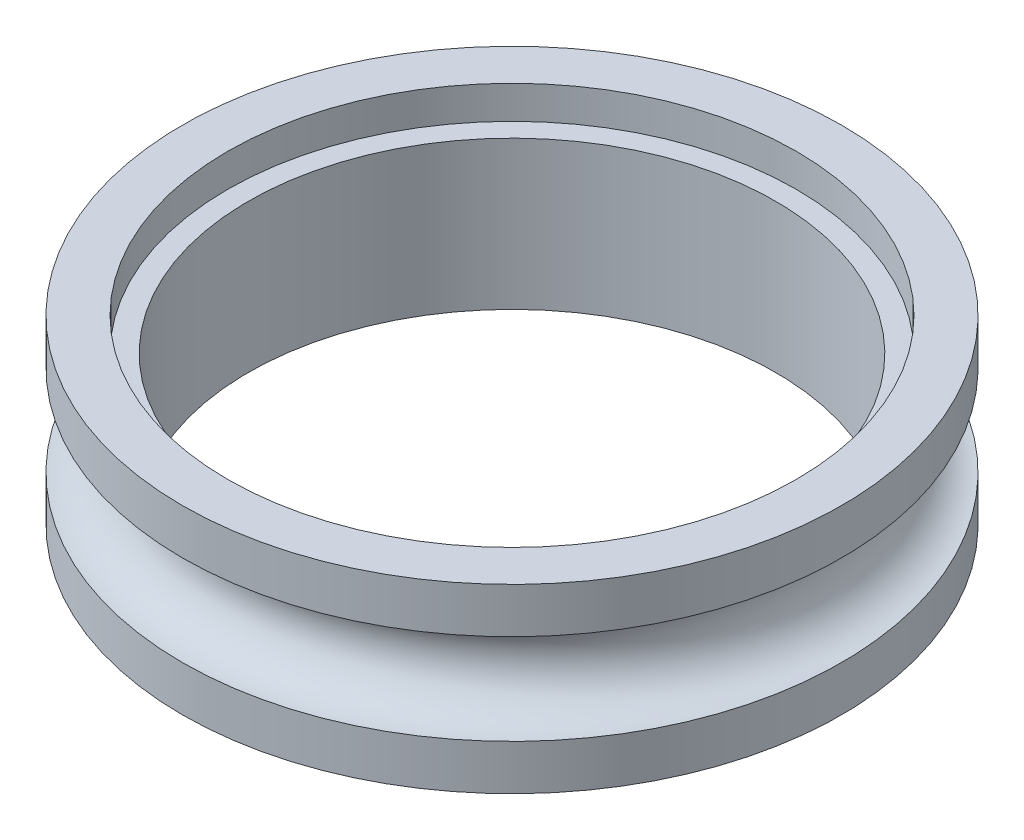
from build123d import *

# Parameters (mm, degrees)
SKETCH1_R           = 10.16
BOSS_EXTRUDE1_DEPTH = 5.588
SKETCH3_R           = 8.128
CUT_EXTRUDE1_DEPTH  = 10.16
SKETCH4_R           = 8.763
CUT_EXTRUDE2_DEPTH  = 1.016


with BuildPart() as part:
    # Sketch1 → Boss-Extrude1 (new body)
    with BuildSketch(Plane(origin=(0, 0, 0), x_dir=(1, 0, 0), z_dir=(0, 1, 0))):
        Circle(SKETCH1_R)
    extrude(amount=BOSS_EXTRUDE1_DEPTH)

    # Sketch2 → Cut-Revolve1 (revolve, cut)
    with BuildSketch(Plane.XY):
        with BuildLine():
            Line((-10.16, 4.191), (-10.16, 1.397))
            ThreePointArc((-10.16, 1.397), (-8.763, 2.794), (-10.16, 4.191))
        make_face()
    revolve(axis=Axis((0, 5.588, 0), (0, -1, 0)), mode=Mode.SUBTRACT)

    # Sketch3 → Cut-Extrude1 (cut)
    with BuildSketch(Plane(origin=(0, 5.588, 0), x_dir=(1, 0, 0), z_dir=(0, 1, 0))):
        Circle(SKETCH3_R)
    extrude(amount=-CUT_EXTRUDE1_DEPTH, mode=Mode.SUBTRACT)

    # Sketch4 → Cut-Extrude2 (cut)
    with BuildSketch(Plane(origin=(0, 5.588, 0), x_dir=(1, 0, 0), z_dir=(0, 1, 0))):
        Circle(SKETCH4_R)
    extrude(amount=-CUT_EXTRUDE2_DEPTH, mode=Mode.SUBTRACT)


solid = part.part
